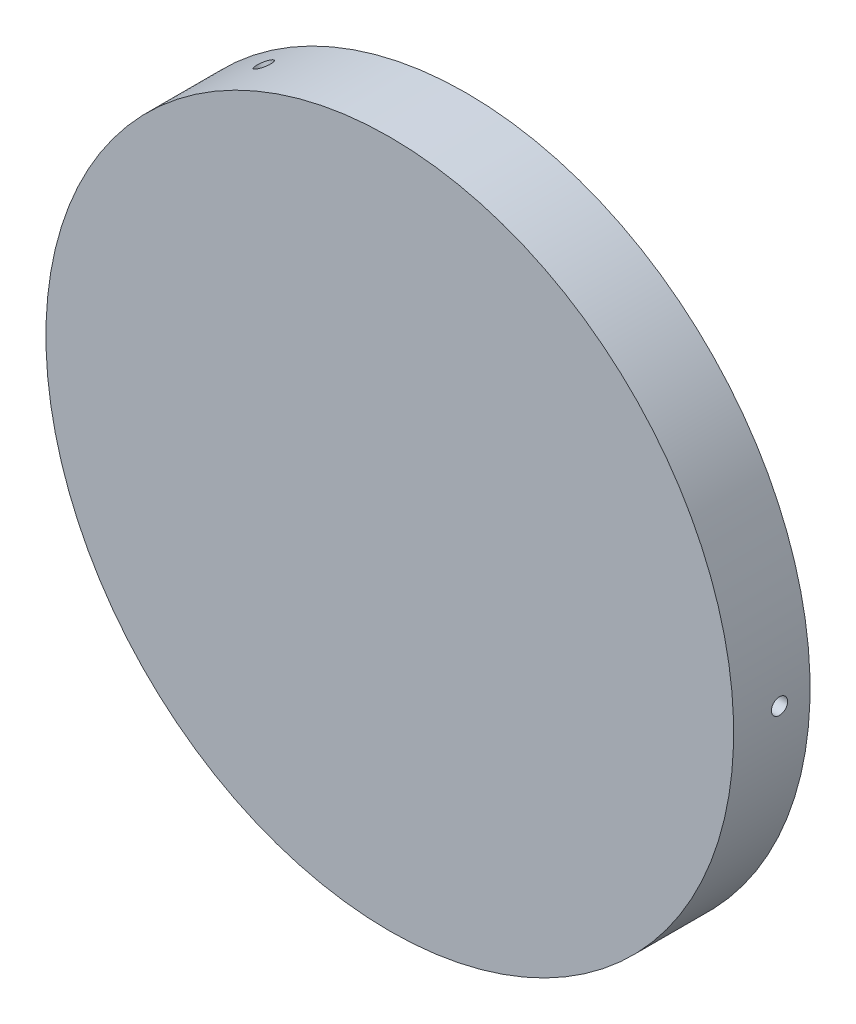
from build123d import *

# Parameters (mm, degrees)
CIRPATTERN1_COUNT = 3


with BuildPart() as part:
    # Sketch1 → Revolve1 (revolve)
    with BuildSketch(Plane(origin=(0, 0, 0), x_dir=(0, 0, -1), z_dir=(1, 0, 0))):
        Polygon((-6.7945, 0), (-11.43, 0), (-11.43, 85.725), (7.62, 85.725), (7.62, 76.2), (-6.7945, 76.2), align=None)
    revolve(axis=Axis((0, 0, 0), (0, 0, 1)))

    # Sketch8 → #10-32 Tapped Hole1 (revolve, cut)
    with BuildSketch(Plane(origin=(85.725, 0, 0), x_dir=(0, 0, -1), z_dir=(0, 1, 0))):
        Polygon((0, 0), (0, 86.937317848), (2.0193, 85.724), (2.0193, 0), align=None)
    f_10_32_tapped_hole1 = revolve(axis=Axis((92.075, 0, 0), (-1, 0, 0)), mode=Mode.SUBTRACT)

    # CirPattern1: #10-32 Tapped Hole1 ×3 about axis
    cirpattern1_axis = Axis((0, 0, 0), (0, 0, -1))
    for i in range(1, CIRPATTERN1_COUNT):
        add(f_10_32_tapped_hole1.rotate(cirpattern1_axis, i * 360 / CIRPATTERN1_COUNT), mode=Mode.SUBTRACT)


solid = part.part
